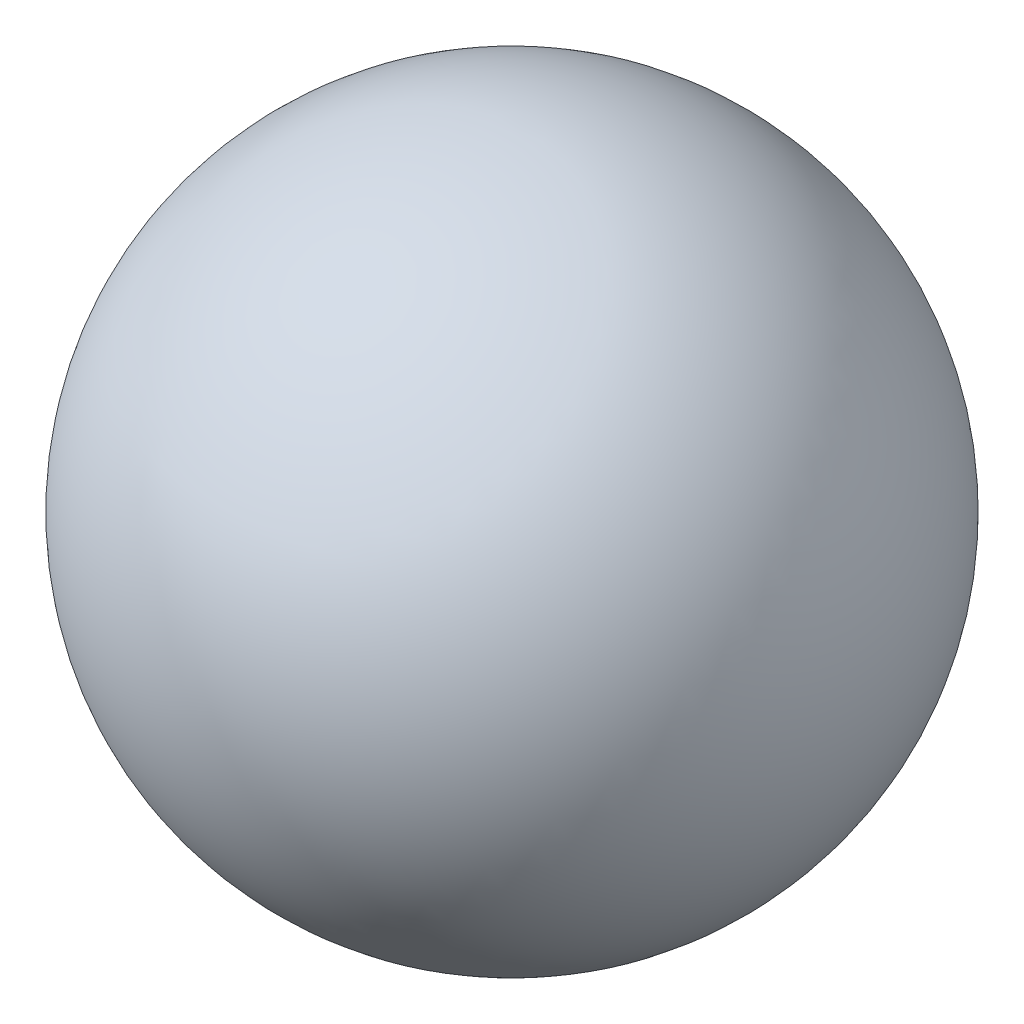
from build123d import *


with BuildPart() as part:
    # Sketch1 one side → Revolve1 (revolve)
    with BuildSketch(Plane.XY):
        with BuildLine():
            Line((0, -20), (0, 20))
            ThreePointArc((0, 20), (-20, 0), (0, -20))
        make_face()
    revolve(axis=Axis((0, 0, 0), (0, 1, 0)))


solid = part.part
